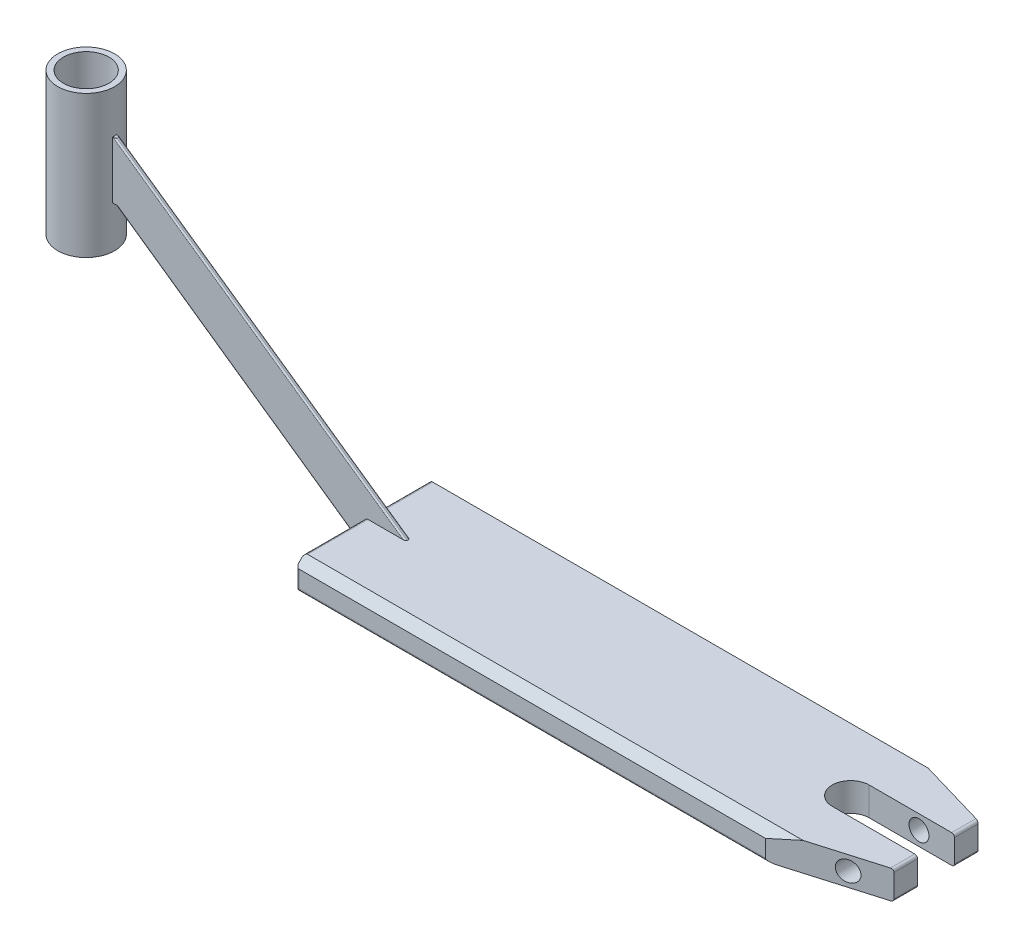
from build123d import *

# Parameters (mm, degrees)
SKETCH1_R               = 20
SKETCH1_R_2             = 16
BOSS_EXTRUDE1_DEPTH     = 100
SKETCH2_W               = 3
SKETCH2_H               = 40
BOSS_EXTRUDE11_DEPTH    = 2
SKETCH3_W               = 3
SKETCH3_H               = 40
BOSS_EXTRUDE12_DEPTH    = 2
BOSS_EXTRUDE13_DEPTH    = 3
FILLET1_R               = 1
SKETCH5_W               = 400
SKETCH5_H               = 100
BOSS_EXTRUDE14_DEPTH    = 20
FILLET2_R               = 2
CUT_EXTRUDE1_DEPTH      = 1
CUT_EXTRUDE1_DEPTH_BACK = 618.662204829
CUT_EXTRUDE2_DEPTH      = 1
CUT_EXTRUDE2_DEPTH_BACK = 618.662204829
CUT_EXTRUDE3_DEPTH      = 21
CUT_EXTRUDE4_DEPTH      = 21
SKETCH11_R              = 7
CUT_EXTRUDE5_DEPTH      = 64
CUT_EXTRUDE5_DEPTH_BACK = 38


with BuildPart() as part:
    # Sketch1 → Boss-Extrude1 (new body)
    with BuildSketch(Plane(origin=(0, 0, 0), x_dir=(1, 0, 0), z_dir=(0, 1, 0))):
        Circle(SKETCH1_R)
        Circle(SKETCH1_R_2, mode=Mode.SUBTRACT)
    extrude(amount=BOSS_EXTRUDE1_DEPTH)

    # Sketch2 → Boss-Extrude11 (add)
    with BuildSketch(Plane(origin=(20, 0, 0), x_dir=(0, 0, -1), z_dir=(1, 0, 0))):
        with Locations((0, 50)):
            Rectangle(SKETCH2_W, SKETCH2_H)
    extrude(amount=-BOSS_EXTRUDE11_DEPTH)

    # Sketch3 → Boss-Extrude12 (add)
    with BuildSketch(Plane(origin=(20, 0, 0), x_dir=(0, 0, -1), z_dir=(1, 0, 0))):
        with Locations((0, 50)):
            Rectangle(SKETCH3_W, SKETCH3_H)
    extrude(amount=BOSS_EXTRUDE12_DEPTH)

    # Sketch4 → Boss-Extrude13 (add)
    with BuildSketch(Plane.XY.offset(1.5)):
        Polygon((22, 70), (254.788125099, -93), (197.662204829, -93), (22, 30), align=None)
    extrude(amount=-BOSS_EXTRUDE13_DEPTH)

    # Fillet1
    fillet1_edges = [part.edges().sort_by_distance(p)[0] for p in [
        (22, 70, 0),
        (138.394062549, -11.5, -1.5),
        (254.788125099, -93, 0),
        (109.831102415, -31.5, -1.5),
        (109.831102415, -31.5, 1.5),
        (138.394062549, -11.5, 1.5),
    ]]
    fillet(fillet1_edges, radius=FILLET1_R)

    # Sketch5 → Boss-Extrude14 (add)
    with BuildSketch(Plane.XZ.offset(93)):
        with Locations((397.662204829, 0)):
            Rectangle(SKETCH5_W, SKETCH5_H)
    extrude(amount=-BOSS_EXTRUDE14_DEPTH)

    # Fillet2
    fillet2_edges = [part.edges().sort_by_distance(p)[0] for p in [
        (197.662204829, -73, -25.75),
        (197.662204829, -83, -50),
        (397.662204829, -73, 50),
        (197.662204829, -83, 50),
        (597.662204829, -73, 0),
        (597.662204829, -83, 50),
        (397.662204829, -73, -50),
        (597.662204829, -83, -50),
        (197.662204829, -73, 25.75),
        (397.662204829, -93, -50),
        (597.662204829, -93, 0),
        (397.662204829, -93, 50),
    ]]
    fillet(fillet2_edges, radius=FILLET2_R)

    # Sketch6 → Cut-Extrude1 (cut, two sides)
    with BuildSketch(Plane(origin=(597.662204829, 0, 0), x_dir=(0, 0, -1), z_dir=(1, 0, 0))) as cut_extrude1_sk:
        Polygon((-52, -81), (-42, -71), (-52, -71), align=None)
    extrude(amount=CUT_EXTRUDE1_DEPTH, mode=Mode.SUBTRACT)
    extrude(cut_extrude1_sk.sketch, amount=-CUT_EXTRUDE1_DEPTH_BACK, mode=Mode.SUBTRACT)

    # Sketch7 → Cut-Extrude2 (cut, two sides)
    with BuildSketch(Plane(origin=(597.662204829, 0, 0), x_dir=(0, 0, -1), z_dir=(1, 0, 0))) as cut_extrude2_sk:
        Polygon((42, -71), (52, -81), (52, -71), align=None)
    extrude(amount=CUT_EXTRUDE2_DEPTH, mode=Mode.SUBTRACT)
    extrude(cut_extrude2_sk.sketch, amount=-CUT_EXTRUDE2_DEPTH_BACK, mode=Mode.SUBTRACT)

    # Sketch8 → Cut-Extrude3 (cut, through all)
    with BuildSketch(Plane(origin=(0, -73, 0), x_dir=(1, 0, 0), z_dir=(0, 1, 0))):
        with BuildLine():
            Line((537.662204829, 13), (597.662204829, 13))
            Line((597.662204829, 13), (597.662204829, -13))
            Line((597.662204829, -13), (537.662204829, -13))
            ThreePointArc((537.662204829, -13), (524.662204829, 0), (537.662204829, 13))
        make_face()
    extrude(amount=-CUT_EXTRUDE3_DEPTH, mode=Mode.SUBTRACT)

    # Sketch9 → Cut-Extrude4 (cut, through all)
    with BuildSketch(Plane(origin=(0, -73, 0), x_dir=(1, 0, 0), z_dir=(0, 1, 0))):
        Polygon((527.662204829, 50), (597.662204829, 50), (597.662204829, 29.5), align=None)
    cut_extrude4 = extrude(amount=-CUT_EXTRUDE4_DEPTH, mode=Mode.SUBTRACT)

    # Mirror1: Cut-Extrude4 across plane
    add(cut_extrude4.mirror(Plane.XY), mode=Mode.SUBTRACT)

    # Sketch11 → Cut-Extrude5 (cut, two sides)
    with BuildSketch(Plane.XY.offset(-13)) as cut_extrude5_sk:
        with Locations((572.662204829, -83)):
            Circle(SKETCH11_R)
    extrude(amount=CUT_EXTRUDE5_DEPTH, mode=Mode.SUBTRACT)
    extrude(cut_extrude5_sk.sketch, amount=-CUT_EXTRUDE5_DEPTH_BACK, mode=Mode.SUBTRACT)


solid = part.part
